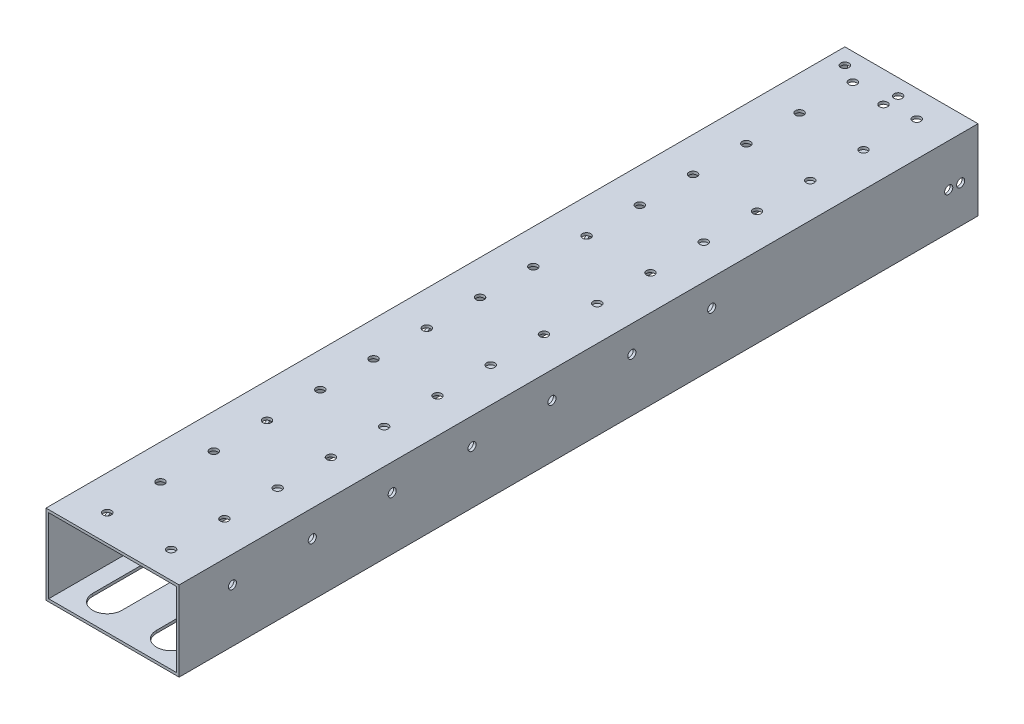
from build123d import *

# Parameters (mm, degrees)
SKETCH_2_W               = 50
SKETCH_2_H               = 30
SKETCH_2_W_2             = 48
SKETCH_2_H_2             = 28
EXTRUDE_1_DEPTH          = 150
SKETCH_3_R               = 1.525
CUT_EXTRUDE_1_DEPTH      = 10
PATTERN_LINEAR_1_COUNT   = 7
PATTERN_LINEAR_1_PITCH   = 30
SKETCH_4_R               = 1.525
CUT_EXTRUDE_2_DEPTH      = 10
PATTERN_LINEAR_2_COUNT   = 15
PATTERN_LINEAR_2_PITCH   = 20
CUT_EXTRUDE_3_DEPTH      = 10
PATTERN_LINEAR_3_COUNT   = 7
PATTERN_LINEAR_3_PITCH   = 40
SKETCH_6_R               = 4
CUT_EXTRUDE_4_DEPTH      = 10
PATTERN_LINEAR_4_COUNT   = 7
PATTERN_LINEAR_4_PITCH   = 30
SKETCH_7_R               = 1.525
CUT_EXTRUDE_5_DEPTH      = 90
SKETCH_8_R               = 1.525
CUT_EXTRUDE_6_DEPTH      = 10
SKETCH_10_R              = 1.525
CUT_EXTRUDE_7_DEPTH      = 51
SKETCH_12_R              = 1.525
CUT_EXTRUDE_9_DEPTH      = 1
CUT_EXTRUDE_9_DEPTH_BACK = 31
SKETCH_14_R              = 1.525
CUT_EXTRUDE_10_DEPTH     = 10


with BuildPart() as part:
    # 草图2 → 凸台-拉伸1 (new body, symmetric)
    with BuildSketch(Plane.XY):
        Rectangle(SKETCH_2_W, SKETCH_2_H)
        Rectangle(SKETCH_2_W_2, SKETCH_2_H_2, mode=Mode.SUBTRACT)
    extrude(amount=EXTRUDE_1_DEPTH, both=True)

    # 草图3 → 切除-拉伸1 (cut)
    with BuildSketch(Plane(origin=(25, 0, 0), x_dir=(0, 0, -1), z_dir=(1, 0, 0))):
        with Locations((-130, 5)):
            Circle(SKETCH_3_R)
    cut_extrude_1 = extrude(amount=-CUT_EXTRUDE_1_DEPTH, mode=Mode.SUBTRACT)

    # 阵列(线性)1: 切除-拉伸1 ×7
    with Locations(*[(0, 0, -i * PATTERN_LINEAR_1_PITCH) for i in range(1, PATTERN_LINEAR_1_COUNT)]):
        add(cut_extrude_1, mode=Mode.SUBTRACT)

    # 草图4 → 切除-拉伸2 (cut)
    with BuildSketch(Plane(origin=(0, 15, 0), x_dir=(1, 0, 0), z_dir=(0, 1, 0))):
        with Locations((-12, 140)):
            Circle(SKETCH_4_R)
        with Locations((12, 140)):
            Circle(SKETCH_4_R)
    cut_extrude_2 = extrude(amount=-CUT_EXTRUDE_2_DEPTH, mode=Mode.SUBTRACT)

    # 阵列(线性)2: 切除-拉伸2 ×15
    with Locations(*[(0, 0, i * PATTERN_LINEAR_2_PITCH) for i in range(1, PATTERN_LINEAR_2_COUNT)]):
        add(cut_extrude_2, mode=Mode.SUBTRACT)

    # 草图5 → 切除-拉伸3 (cut)
    with BuildSketch(Plane(origin=(0, -14, 0), x_dir=(1, 0, 0), z_dir=(0, 1, 0))):
        with BuildLine():
            Line((-17.5, -140), (-17.5, -120))
            ThreePointArc((-17.5, -120), (-12, -114.5), (-6.5, -120))
            Line((-6.5, -120), (-6.5, -140))
            ThreePointArc((-6.5, -140), (-12, -145.5), (-17.5, -140))
        make_face()
        with BuildLine():
            Line((17.5, -140), (17.5, -120))
            ThreePointArc((17.5, -120), (12, -114.5), (6.5, -120))
            Line((6.5, -120), (6.5, -140))
            ThreePointArc((6.5, -140), (12, -145.5), (17.5, -140))
        make_face()
    cut_extrude_3 = extrude(amount=-CUT_EXTRUDE_3_DEPTH, mode=Mode.SUBTRACT)

    # 阵列(线性)3: 切除-拉伸3 ×7
    with Locations(*[(0, 0, -i * PATTERN_LINEAR_3_PITCH) for i in range(1, PATTERN_LINEAR_3_COUNT)]):
        add(cut_extrude_3, mode=Mode.SUBTRACT)

    # 草图6 → 切除-拉伸4 (cut)
    with BuildSketch(Plane(origin=(-24, 0, 0), x_dir=(0, 0, -1), z_dir=(1, 0, 0))):
        with Locations((-130, 5)):
            Circle(SKETCH_6_R)
    cut_extrude_4 = extrude(amount=-CUT_EXTRUDE_4_DEPTH, mode=Mode.SUBTRACT)

    # 阵列(线性)4: 切除-拉伸4 ×7
    with Locations(*[(0, 0, -i * PATTERN_LINEAR_4_PITCH) for i in range(1, PATTERN_LINEAR_4_COUNT)]):
        add(cut_extrude_4, mode=Mode.SUBTRACT)

    # 草图7 → 切除-拉伸5 (cut)
    with BuildSketch(Plane.XZ.offset(15)):
        with Locations((-19, -144)):
            Circle(SKETCH_7_R)
        with Locations((1, -144)):
            Circle(SKETCH_7_R)
    extrude(amount=-CUT_EXTRUDE_5_DEPTH, mode=Mode.SUBTRACT)

    # 草图8 → 切除-拉伸6 (cut)
    with BuildSketch(Plane.XZ.offset(15)):
        with Locations((19, -10)):
            Circle(SKETCH_8_R)
        with Locations((-19, -10)):
            Circle(SKETCH_8_R)
        with Locations((-19, -90)):
            Circle(SKETCH_8_R)
        with Locations((19, -90)):
            Circle(SKETCH_8_R)
        with Locations((-19, 70)):
            Circle(SKETCH_8_R)
        with Locations((19, 70)):
            Circle(SKETCH_8_R)
    extrude(amount=-CUT_EXTRUDE_6_DEPTH, mode=Mode.SUBTRACT)

    # 草图10 → 切除-拉伸7 (cut, through all)
    with BuildSketch(Plane(origin=(25, 0, 0), x_dir=(0, 0, -1), z_dir=(1, 0, 0))):
        with Locations((139, -1)):
            Circle(SKETCH_10_R)
    extrude(amount=-CUT_EXTRUDE_7_DEPTH, mode=Mode.SUBTRACT)

    # 草图12 → 切除-拉伸9 (cut, two sides)
    with BuildSketch(Plane.XZ.offset(15)) as cut_extrude_9_sk:
        with Locations((1, -138.5)):
            Circle(SKETCH_12_R)
    extrude(amount=CUT_EXTRUDE_9_DEPTH, mode=Mode.SUBTRACT)
    extrude(cut_extrude_9_sk.sketch, amount=-CUT_EXTRUDE_9_DEPTH_BACK, mode=Mode.SUBTRACT)

    # 草图14 → 切除-拉伸10 (cut)
    with BuildSketch(Plane(origin=(25, 0, 0), x_dir=(0, 0, -1), z_dir=(1, 0, 0))):
        with Locations((143.5, -1)):
            Circle(SKETCH_14_R)
    extrude(amount=-CUT_EXTRUDE_10_DEPTH, mode=Mode.SUBTRACT)


solid = part.part
